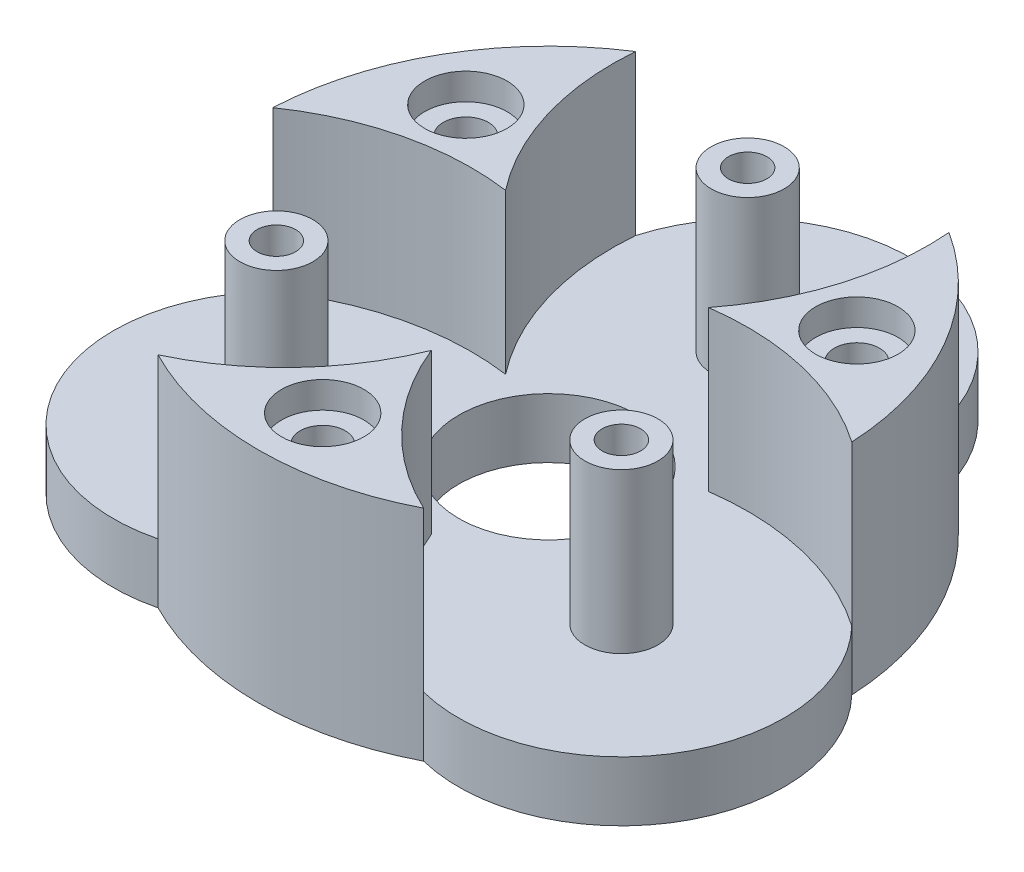
from build123d import *

# Parameters (mm, degrees)
CROQUIS1_R                     = 21.825
SALIENTE_EXTRUIR1_DEPTH        = 4.5
CROQUIS2_R                     = 2.75
SALIENTE_EXTRUIR2_DEPTH        = 12
TALADRO_DE_MARGEN_PARA_M121_D  = 13.5
SALIENTE_EXTRUIR3_DEPTH        = 12
CROQUIS8_R                     = 1.7
CORTAR_EXTRUIR1_DEPTH          = 16.5
MATRIZC1_COUNT                 = 3
TALADRO_DE_MARGEN_PARA_M2_51_D = 2.9
SALIENTE_EXTRUIR5_DEPTH        = 4.5
MATRIZC2_COUNT                 = 3
CROQUIS12_R                    = 2.875
CORTAR_EXTRUIR2_DEPTH          = 2.2
CROQUIS13_R                    = 3.1
CORTAR_EXTRUIR3_DEPTH          = 2
CROQUIS14_R                    = 3.1
CORTAR_EXTRUIR4_DEPTH          = 3.5


with BuildPart() as part:
    # Croquis1 → Saliente-Extruir1 (new body)
    with BuildSketch(Plane(origin=(0, 0, 0), x_dir=(1, 0, 0), z_dir=(0, 1, 0))):
        Circle(CROQUIS1_R)
    extrude(amount=SALIENTE_EXTRUIR1_DEPTH)

    # Croquis2 → Saliente-Extruir2 (add)
    with BuildSketch(Plane(origin=(0, 4.5, 0), x_dir=(1, 0, 0), z_dir=(0, 1, 0))):
        with Locations((0, 15)):
            Circle(CROQUIS2_R)
        with Locations((12.990381057, -7.5)):
            Circle(CROQUIS2_R)
        with Locations((-12.990381057, -7.5)):
            Circle(CROQUIS2_R)
    extrude(amount=SALIENTE_EXTRUIR2_DEPTH)

    # Taladro de margen para M121 (through all)
    with Locations(Plane(origin=(0, 4.5, 0), x_dir=(1, 0, 0), z_dir=(0, 1, 0))):
        with Locations((0, 0)):
            Hole(TALADRO_DE_MARGEN_PARA_M121_D / 2)

    # Croquis5 → Saliente-Extruir3 (add)
    with BuildSketch(Plane(origin=(0, 4.5, 0), x_dir=(1, 0, 0), z_dir=(0, 1, 0))):
        with BuildLine():
            ThreePointArc((-7.642674188, 4.4125), (-11.035446071, 10.994501306), (-11.800237164, 18.359875487))
            ThreePointArc((-11.800237164, 18.359875487), (-18.901004438, 10.9125), (-21.800237164, 1.039367411))
            ThreePointArc((-21.800237164, 1.039367411), (-15.039240468, 4.059725986), (-7.642674188, 4.4125))
        make_face()
    saliente_extruir3 = extrude(amount=SALIENTE_EXTRUIR3_DEPTH)

    # Croquis8 → Cortar-Extruir1 (cut)
    with BuildSketch(Plane(origin=(0, 16.5, 0), x_dir=(1, 0, 0), z_dir=(0, 1, 0))):
        with Locations((-14.722431864, 8.5)):
            Circle(CROQUIS8_R)
    cortar_extruir1 = extrude(amount=-CORTAR_EXTRUIR1_DEPTH, mode=Mode.SUBTRACT)

    # MatrizC1: Saliente-Extruir3, Cortar-Extruir1 ×3 about axis
    matrizc1_axis = Axis((0, 0, 0), (0, 1, 0))
    for i in range(1, MATRIZC1_COUNT):
        add(saliente_extruir3.rotate(matrizc1_axis, i * 360 / MATRIZC1_COUNT))
        add(cortar_extruir1.rotate(matrizc1_axis, i * 360 / MATRIZC1_COUNT), mode=Mode.SUBTRACT)

    # Taladro de margen para M2.51 (through all)
    with Locations(Plane(origin=(0, 16.5, 0), x_dir=(1, 0, 0), z_dir=(0, 1, 0))):
        with Locations((12.990381057, -7.5), (-12.990381057, -7.5), (0, 15)):
            Hole(TALADRO_DE_MARGEN_PARA_M2_51_D / 2)

    # Croquis11 → Saliente-Extruir5 (add)
    with BuildSketch(Plane.XZ):
        with BuildLine():
            ThreePointArc((-10, 19.399242898), (-18.901004438, 10.9125), (-21.800237164, -1.039367411))
            ThreePointArc((-21.800237164, -1.039367411), (-23.615858472, 13.634622246), (-10, 19.399242898))
        make_face()
    saliente_extruir5 = extrude(amount=-SALIENTE_EXTRUIR5_DEPTH)

    # MatrizC2: Saliente-Extruir5 ×3 about axis
    matrizc2_axis = Axis((0, 0, 0), (0, 1, 0))
    for i in range(1, MATRIZC2_COUNT):
        add(saliente_extruir5.rotate(matrizc2_axis, i * 360 / MATRIZC2_COUNT))

    # Croquis12 → Cortar-Extruir2 (cut)
    with BuildSketch(Plane.XZ):
        with Locations((-12.990381057, 7.5)):
            Circle(CROQUIS12_R)
        with Locations((12.990381057, 7.5)):
            Circle(CROQUIS12_R)
        with Locations((0, -15)):
            Circle(CROQUIS12_R)
    extrude(amount=-CORTAR_EXTRUIR2_DEPTH, mode=Mode.SUBTRACT)

    # Croquis13 → Cortar-Extruir3 (cut)
    with BuildSketch(Plane(origin=(0, 16.5, 0), x_dir=(1, 0, 0), z_dir=(0, 1, 0))):
        with Locations((0, -17)):
            Circle(CROQUIS13_R)
        with Locations((-14.722431864, 8.5)):
            Circle(CROQUIS13_R)
        with Locations((14.722431864, 8.5)):
            Circle(CROQUIS13_R)
    extrude(amount=-CORTAR_EXTRUIR3_DEPTH, mode=Mode.SUBTRACT)

    # Croquis14 → Cortar-Extruir4 (cut)
    with BuildSketch(Plane.XZ):
        with Locations((-14.722431864, -8.5)):
            Circle(CROQUIS14_R)
    extrude(amount=-CORTAR_EXTRUIR4_DEPTH, mode=Mode.SUBTRACT)


solid = part.part
